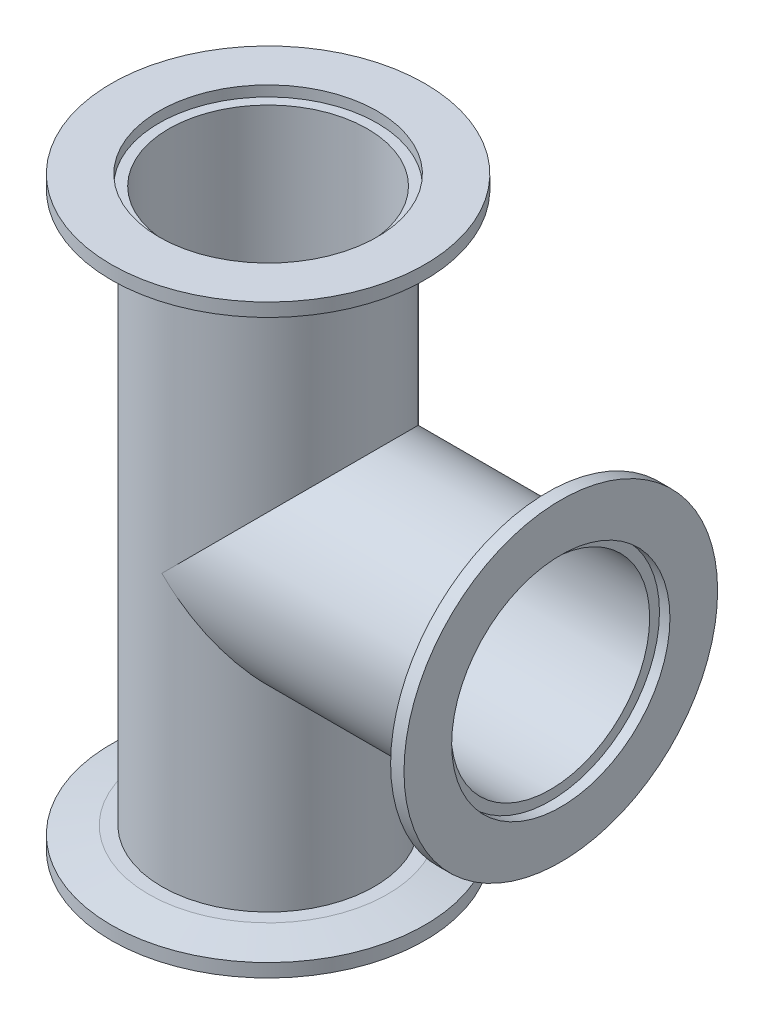
from build123d import *

# Parameters (mm, degrees)
SKETCH5_R         = 25.4
STUB_DEPTH        = 67.5
CIRPATTERN1_COUNT = 3
CIRPATTERN1_ANGLE = 180
BORE_SKETCH_R     = 23.75
BORE_DEPTH        = 71
CIRPATTERN2_COUNT = 3
CIRPATTERN2_ANGLE = 180


with BuildPart() as part:
    # Sketch1 → Flange (revolve)
    with BuildSketch(Plane(origin=(0, 0, 0), x_dir=(0, 0, -1), z_dir=(1, 0, 0))):
        Polygon((-37.5, -70), (-37.5, -66.8), (-28.561202792, -64.9), (0, -64.9), (0, -67.5), (-26.1, -67.5), (-26.1, -70), align=None)
    revolve(axis=Axis((0, 0, 0), (0, -1, 0)))

    # Sketch5 → Stub (add)
    with BuildSketch(Plane.XZ.offset(67.5)):
        Circle(SKETCH5_R)
    extrude(amount=-STUB_DEPTH)


with BuildPart() as cirpattern1_1:
    # CirPattern1: pattern copy
    add(part.part.rotate(Axis((0, 0, 0), (0, 0, 1)), 1 * CIRPATTERN1_ANGLE / (CIRPATTERN1_COUNT - 1)))


with BuildPart() as cirpattern1_2:
    # CirPattern1: pattern copy
    add(part.part.rotate(Axis((0, 0, 0), (0, 0, 1)), 2 * CIRPATTERN1_ANGLE / (CIRPATTERN1_COUNT - 1)))


with BuildPart() as part_1:
    add(part.part)

    # Combine1: union CirPattern1_1, CirPattern1_2
    add(cirpattern1_1.part)
    add(cirpattern1_2.part)

    # Bore Sketch → Bore (cut, through all)
    with BuildSketch(Plane(origin=(0, 0, 0), x_dir=(1, 0, 0), z_dir=(0, 1, 0))):
        Circle(BORE_SKETCH_R)
    bore = extrude(amount=-BORE_DEPTH, mode=Mode.SUBTRACT)

    # CirPattern2: Bore ×3 about axis
    cirpattern2_axis = Axis((0, 0, -30.25), (0, 0, 1))
    for i in range(1, CIRPATTERN2_COUNT):
        add(bore.rotate(cirpattern2_axis, i * CIRPATTERN2_ANGLE / (CIRPATTERN2_COUNT - 1)), mode=Mode.SUBTRACT)


solid = part_1.part
